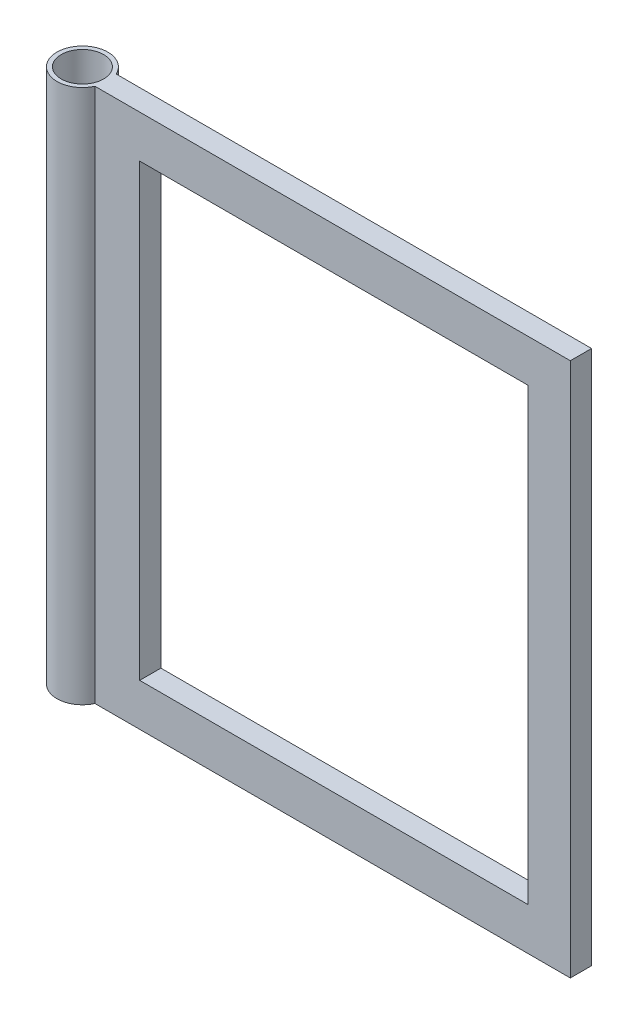
from build123d import *

# Parameters (mm, degrees)
SKETCH1_W           = 10
SKETCH1_H           = 1260
SKETCH2_W           = 1115
SKETCH2_H           = 1260
SKETCH2_W_2         = 915
SKETCH2_H_2         = 1060
BOSS_EXTRUDE1_DEPTH = 25
SKETCH3_W           = 50
SKETCH3_H           = 1260
BOSS_EXTRUDE2_DEPTH = 10


with BuildPart() as part:
    # Sketch1 → Revolve1 (revolve)
    with BuildSketch(Plane.XY):
        with Locations((-55, 630)):
            Rectangle(SKETCH1_W, SKETCH1_H)
    revolve(axis=Axis((0, 0, 0), (0, 1, 0)))



with BuildPart() as body_2:
    # Sketch2 → Boss-Extrude1 (new body, symmetric)
    with BuildSketch(Plane.XY):
        with Locations((617.5, 630)):
            Rectangle(SKETCH2_W, SKETCH2_H)
        with Locations((617.5, 630)):
            Rectangle(SKETCH2_W_2, SKETCH2_H_2, mode=Mode.SUBTRACT)
    extrude(amount=BOSS_EXTRUDE1_DEPTH, both=True)


with BuildPart() as part_1:
    add(part.part)

    add(body_2.part)  # Boss-Extrude2 merges body 2
    # Sketch3 → Boss-Extrude2 (add)
    with BuildSketch(Plane.ZY.offset(-60)):
        with Locations((0, 630)):
            Rectangle(SKETCH3_W, SKETCH3_H)
    extrude(amount=BOSS_EXTRUDE2_DEPTH)


solid = part_1.part
